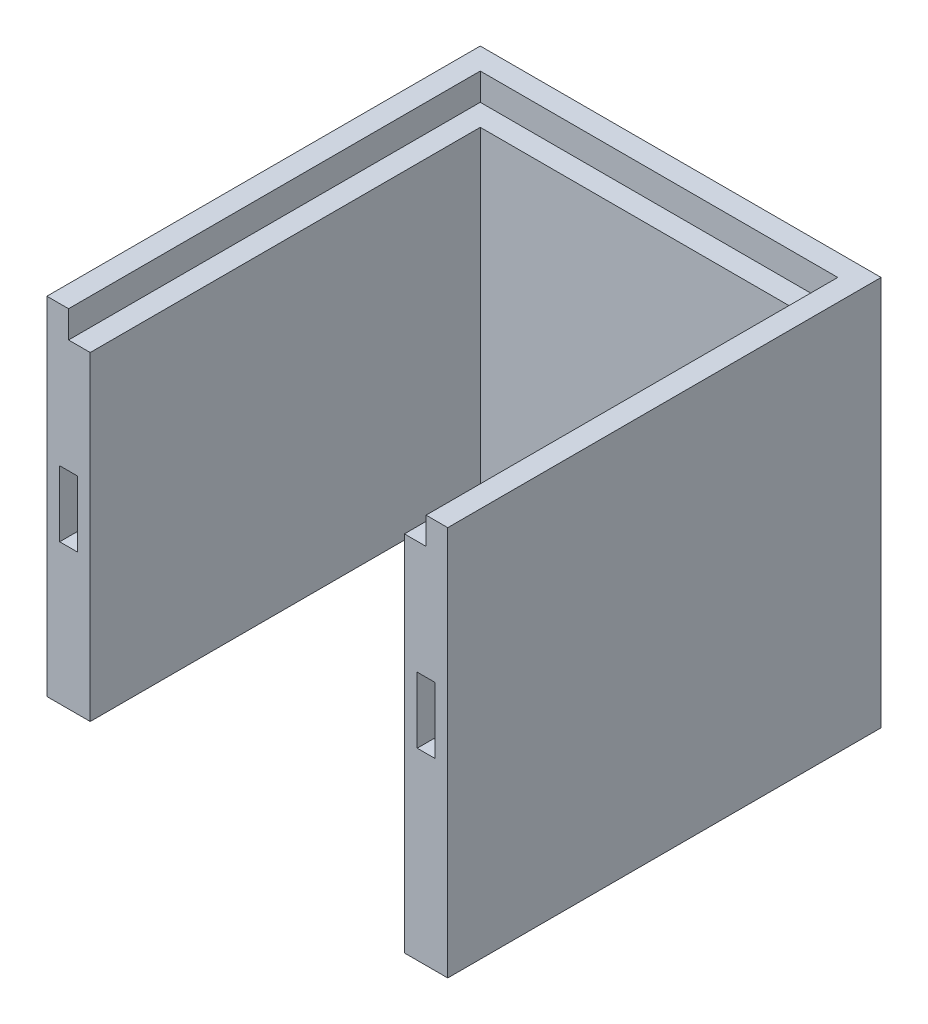
from build123d import *

# Parameters (mm, degrees)
SKETCH1_W            = 185
SKETCH1_H            = 160
BOSS_EXTRUDE1_DEPTH  = 20
SKETCH2_W            = 20
SKETCH2_H            = 160
BOSS_EXTRUDE2_DEPTH  = 180
SKETCH4_W            = 50
SKETCH4_H            = 50
CUT_EXTRUDE1_DEPTH   = 201
SKETCH3_W            = 20
SKETCH3_H            = 200
BOSS_EXTRUDE3_DEPTH  = 20
FILLET1_R            = 5
SKETCH6_W            = 8.2
SKETCH6_H            = 30.4
CUT_EXTRUDE2_DEPTH   = 12.5
FILLET2_R            = 5
FILLET2_OF_MIRROR1_R = 5
SKETCH7_W            = 165
SKETCH7_H            = 190
CUT_EXTRUDE3_DEPTH   = 12.5


with BuildPart() as part:
    # Sketch1 → Boss-Extrude1 (new body)
    with BuildSketch(Plane.XY):
        with Locations((92.5, 80)):
            Rectangle(SKETCH1_W, SKETCH1_H)
    extrude(amount=BOSS_EXTRUDE1_DEPTH)

    # Sketch2 → Boss-Extrude2 (add)
    with BuildSketch(Plane.XY.offset(20)):
        with Locations((10, 80)):
            Rectangle(SKETCH2_W, SKETCH2_H)
        with Locations((175, 80)):
            Rectangle(SKETCH2_W, SKETCH2_H)
    extrude(amount=BOSS_EXTRUDE2_DEPTH)

    # Sketch4 → Cut-Extrude1 (cut, through all)
    with BuildSketch(Plane(origin=(0, 0, 0), x_dir=(-1, 0, 0), z_dir=(0, 0, -1))):
        with Locations((-92.5, 25)):
            Rectangle(SKETCH4_W, SKETCH4_H)
    extrude(amount=-CUT_EXTRUDE1_DEPTH, mode=Mode.SUBTRACT)

    # Sketch3 → Boss-Extrude3 (add)
    with BuildSketch(Plane.XZ):
        with Locations((175, 100)):
            Rectangle(SKETCH3_W, SKETCH3_H)
    extrude(amount=BOSS_EXTRUDE3_DEPTH)

    # Fillet1
    fillet1_edges = [part.edges().sort_by_distance(p)[0] for p in [
        (67.5, 50, 10),
        (67.5, 0, 10),
        (117.5, 0, 10),
        (117.5, 50, 10),
        (165, 0, 10),
    ]]
    fillet(fillet1_edges, radius=FILLET1_R)

    # Sketch6 → Cut-Extrude2 (cut)
    with BuildSketch(Plane.XY.offset(200)):
        with Locations((10, 80)):
            Rectangle(SKETCH6_W, SKETCH6_H)
    cut_extrude2 = extrude(amount=-CUT_EXTRUDE2_DEPTH, mode=Mode.SUBTRACT)

    # Fillet2
    fillet2_edges = [part.edges().sort_by_distance(p)[0] for p in [
        (10, 64.8, 187.5),
        (10, 95.2, 187.5),
    ]]
    fillet(fillet2_edges, radius=FILLET2_R)

    # Mirror1: Cut-Extrude2 across plane
    add(cut_extrude2.mirror(Plane(origin=(92.5, 0, 0), x_dir=(0, 0, 1), z_dir=(1, 0, 0))), mode=Mode.SUBTRACT)

    # Fillet2 of Mirror1
    fillet2_of_mirror1_edges = [part.edges().sort_by_distance(p)[0] for p in [
        (175, 64.8, 187.5),
        (175, 95.2, 187.5),
    ]]
    fillet(fillet2_of_mirror1_edges, radius=FILLET2_OF_MIRROR1_R)

    # Sketch7 → Cut-Extrude3 (cut)
    with BuildSketch(Plane(origin=(0, 160, 0), x_dir=(1, 0, 0), z_dir=(0, 1, 0))):
        with Locations((92.5, -105)):
            Rectangle(SKETCH7_W, SKETCH7_H)
    extrude(amount=-CUT_EXTRUDE3_DEPTH, mode=Mode.SUBTRACT)


solid = part.part
